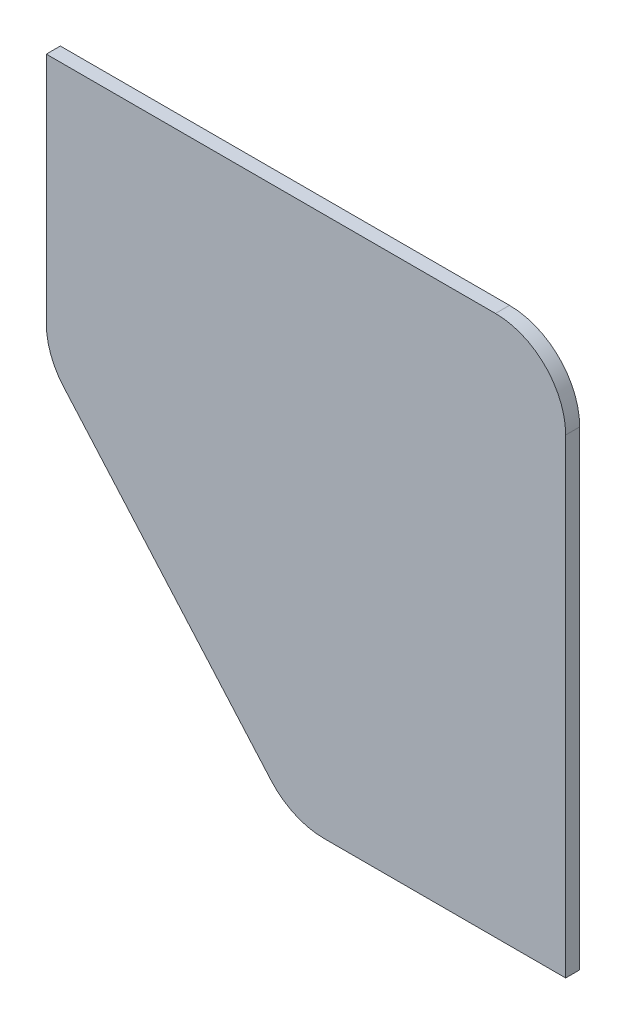
from build123d import *

# Parameters (mm, degrees)
ESBO_O1_W                  = 74
ESBO_O1_H                  = 77
RESSALTO_EXTRUS_O1_DEPTH   = 2
CORTE_EXTRUS_O1_DEPTH      = 1
CORTE_EXTRUS_O1_DEPTH_BACK = 3
FILETE1_R                  = 10
FILETE2_R                  = 10
FILETE3_R                  = 10


with BuildPart() as part:
    # Esboço1 → Ressalto-extrusão1 (new body)
    with BuildSketch(Plane.XY):
        with Locations((-49.165685596, 5.526315789)):
            Rectangle(ESBO_O1_W, ESBO_O1_H)
    extrude(amount=RESSALTO_EXTRUS_O1_DEPTH)

    # Esboço2 → Corte-extrusão1 (cut, two sides)
    with BuildSketch(Plane.XY.offset(2)) as corte_extrus_o1_sk:
        Polygon((69.094880688, -170.414331392), (-51.165685596, -32.973684211), (-86.165685596, 7.026315789), (-206.426251879, 144.46696297), (-481.307546241, -96.054169596), (-205.786413674, -410.935463958), align=None)
    extrude(amount=CORTE_EXTRUS_O1_DEPTH, mode=Mode.SUBTRACT)
    extrude(corte_extrus_o1_sk.sketch, amount=-CORTE_EXTRUS_O1_DEPTH_BACK, mode=Mode.SUBTRACT)

    # Filete1
    filete1_edges = [part.edges().sort_by_distance(p)[0] for p in [
        (-86.165685596, 7.026315789, 1),
    ]]
    fillet(filete1_edges, radius=FILETE1_R)

    # Filete2
    filete2_edges = [part.edges().sort_by_distance(p)[0] for p in [
        (-51.165685596, -32.973684211, 1),
    ]]
    fillet(filete2_edges, radius=FILETE2_R)

    # Filete3
    filete3_edges = [part.edges().sort_by_distance(p)[0] for p in [
        (-12.165685596, 44.026315789, 1),
    ]]
    fillet(filete3_edges, radius=FILETE3_R)


solid = part.part
